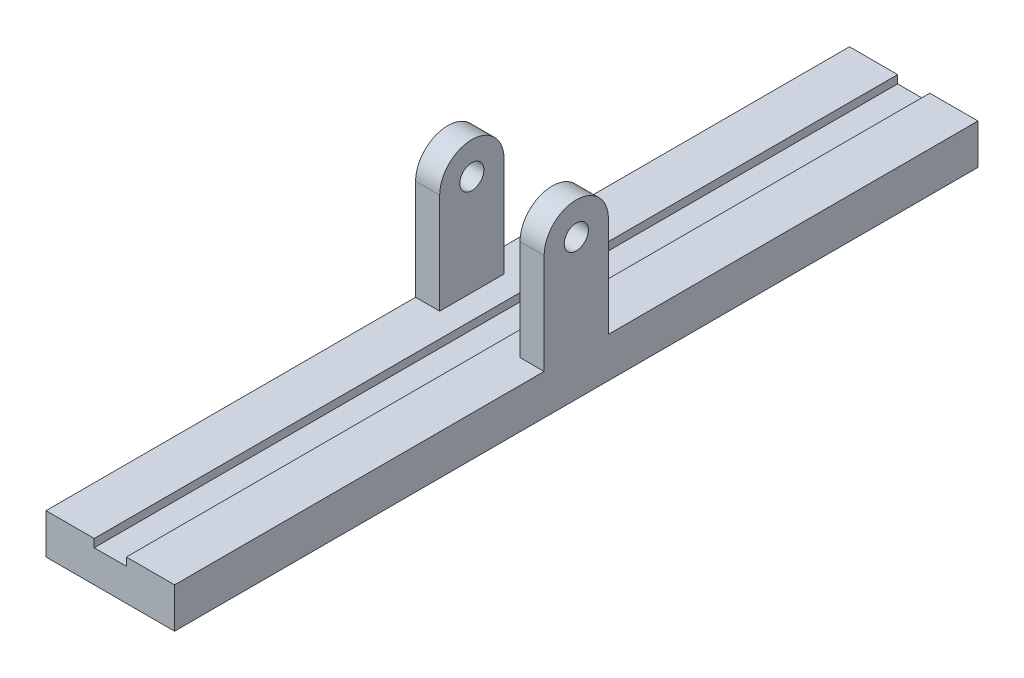
from build123d import *

# Parameters (mm, degrees)
Y_KSEKLIK_EKSTR_ZYON1_DEPTH = 250
IZIM3_R                     = 7.5
Y_KSEKLIK_EKSTR_ZYON3_DEPTH = 15


with BuildPart() as part:
    # Çizim2 → Yükseklik-Ekstrüzyon1 (new body, symmetric)
    with BuildSketch(Plane.XY):
        Polygon((10, 25), (40, 25), (40, 0), (-40, 0), (-40, 25), (-10, 25), (-10, 20), (10, 20), align=None)
    extrude(amount=Y_KSEKLIK_EKSTR_ZYON1_DEPTH, both=True)

    # Çizim3 → Yükseklik-Ekstrüzyon3 (add)
    with BuildSketch(Plane(origin=(40, 0, 0), x_dir=(0, 0, -1), z_dir=(1, 0, 0))):
        with BuildLine():
            Line((-20, 25), (20, 25))
            Line((20, 25), (20, 87.5))
            ThreePointArc((20, 87.5), (0, 107.5), (-20, 87.5))
            Line((-20, 87.5), (-20, 25))
        make_face()
        with Locations((0, 87.5)):
            Circle(IZIM3_R, mode=Mode.SUBTRACT)
    y_kseklik_ekstr_zyon3 = extrude(amount=-Y_KSEKLIK_EKSTR_ZYON3_DEPTH)

    # Aynalama1: Yükseklik-Ekstrüzyon3 across plane
    add(y_kseklik_ekstr_zyon3.mirror(Plane.ZY))


solid = part.part
